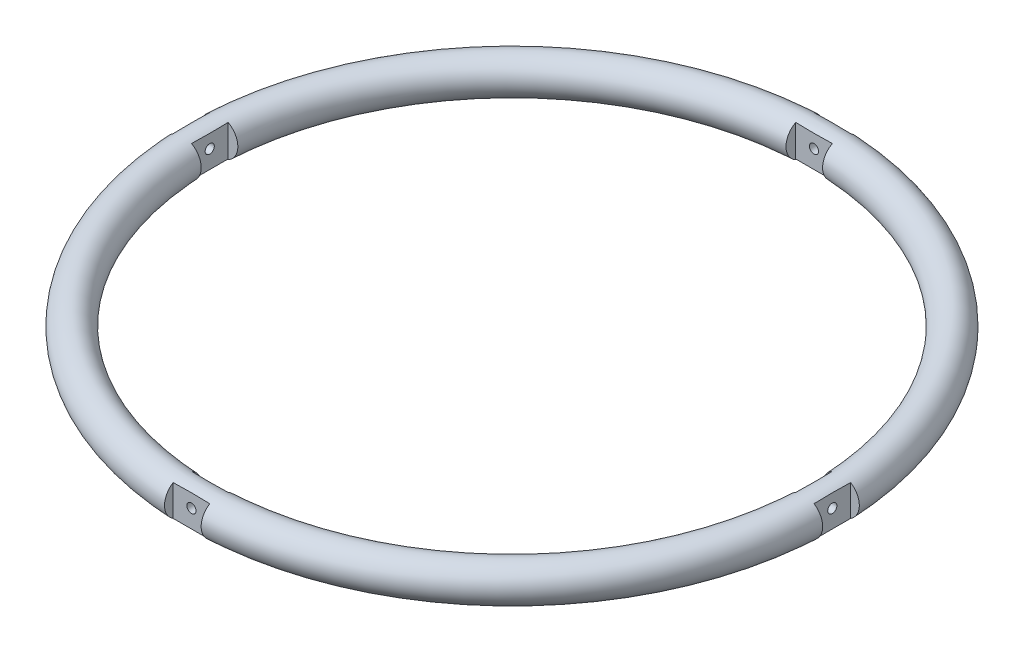
from build123d import *
from build123d.topology import SkipClean

# Parameters (mm, degrees)
SKETCH1_R          = 4
SKETCH2_W          = 62
SKETCH2_H          = 8
SKETCH2_W_2        = 8
SKETCH2_H_2        = 62
CUT_EXTRUDE1_DEPTH = 103.137162827
SKETCH3_W          = 5
SKETCH3_H          = 8
CUT_EXTRUDE2_DEPTH = 103.137162827
CIRPATTERN1_COUNT  = 4
SKETCH4_W          = 8
SKETCH4_H          = 5.236215915
CUT_EXTRUDE3_DEPTH = 160.111383838
SKETCH5_W          = 8
SKETCH5_H          = 5.684867593
CUT_EXTRUDE4_DEPTH = 160.111383838
SKETCH6_R          = 1
CUT_EXTRUDE5_DEPTH = 160.111383838
SKETCH7_R          = 1
CUT_EXTRUDE6_DEPTH = 160.111383838


with BuildPart() as part:
    # Sketch1 → Revolve1 (revolve)
    with BuildSketch(Plane.XY, mode=Mode.PRIVATE) as revolve1_sk:
        with Locations((68, 0)):
            Circle(SKETCH1_R)
    revolve(revolve1_sk.sketch.rotate(Axis((0, 28.887246591, 0), (0, -1, 0)), 180), axis=Axis((0, 28.887246591, 0), (0, -1, 0)))

    # Sketch2 → Cut-Extrude1 (cut, through all)
    with BuildSketch(Plane(origin=(0, 4, 0), x_dir=(1, 0, 0), z_dir=(0, 1, 0))):
        with Locations((-35, 0)):
            Rectangle(SKETCH2_W, SKETCH2_H)
        with Locations((0, 35)):
            Rectangle(SKETCH2_W_2, SKETCH2_H_2)
        with Locations((35, 0)):
            Rectangle(SKETCH2_W, SKETCH2_H)
        with Locations((0, -35)):
            Rectangle(SKETCH2_W_2, SKETCH2_H_2)
        Rectangle(SKETCH2_W_2, SKETCH2_H)
    extrude(amount=-CUT_EXTRUDE1_DEPTH, mode=Mode.SUBTRACT)

    # Sketch3 → Cut-Extrude2 (cut, through all)
    with BuildSketch(Plane(origin=(0, 4, 0), x_dir=(1, 0, 0), z_dir=(0, 1, 0))):
        with Locations((72.5, 0)):
            Rectangle(SKETCH3_W, SKETCH3_H)
    cut_extrude2 = extrude(amount=-CUT_EXTRUDE2_DEPTH, mode=Mode.SUBTRACT)

    # CirPattern1: Cut-Extrude2 ×4 about axis
    cirpattern1_axis = Axis((0, 0, 0), (0, 1, 0))
    for i in range(1, CIRPATTERN1_COUNT):
        add(cut_extrude2.rotate(cirpattern1_axis, i * 360 / CIRPATTERN1_COUNT), mode=Mode.SUBTRACT)

    # Sketch4 → Cut-Extrude3 (cut, through all)
    with SkipClean():  # the faces are left unmerged after this step: merging them gives an invalid solid
        with BuildSketch(Plane.XY.offset(70)):
            with Locations((0, -6.013721271)):
                Rectangle(SKETCH4_W, SKETCH4_H)
        extrude(amount=-CUT_EXTRUDE3_DEPTH, mode=Mode.SUBTRACT)

    # Sketch5 → Cut-Extrude4 (cut, through all)
    with SkipClean():  # the faces are left unmerged after this step: merging them gives an invalid solid
        with BuildSketch(Plane.ZY.offset(70)):
            with Locations((0, -6.23804711)):
                Rectangle(SKETCH5_W, SKETCH5_H)
        extrude(amount=-CUT_EXTRUDE4_DEPTH, mode=Mode.SUBTRACT)

    # Sketch6 → Cut-Extrude5 (cut, through all)
    with SkipClean():  # the faces are left unmerged after this step: merging them gives an invalid solid
        with BuildSketch(Plane(origin=(0, 0, -70), x_dir=(-1, 0, 0), z_dir=(0, 0, -1))):
            with Locations((0.0078786, 0.529643933)):
                Circle(SKETCH6_R)
        extrude(amount=-CUT_EXTRUDE5_DEPTH, mode=Mode.SUBTRACT)

    # Sketch7 → Cut-Extrude6 (cut, through all)
    with SkipClean():  # the faces are left unmerged after this step: merging them gives an invalid solid
        with BuildSketch(Plane.ZY.offset(70)):
            with Locations(Location((0.0078786, 0.529643933, 0), (0, 0, 270))):
                Circle(SKETCH7_R)
        extrude(amount=-CUT_EXTRUDE6_DEPTH, mode=Mode.SUBTRACT)


solid = part.part
